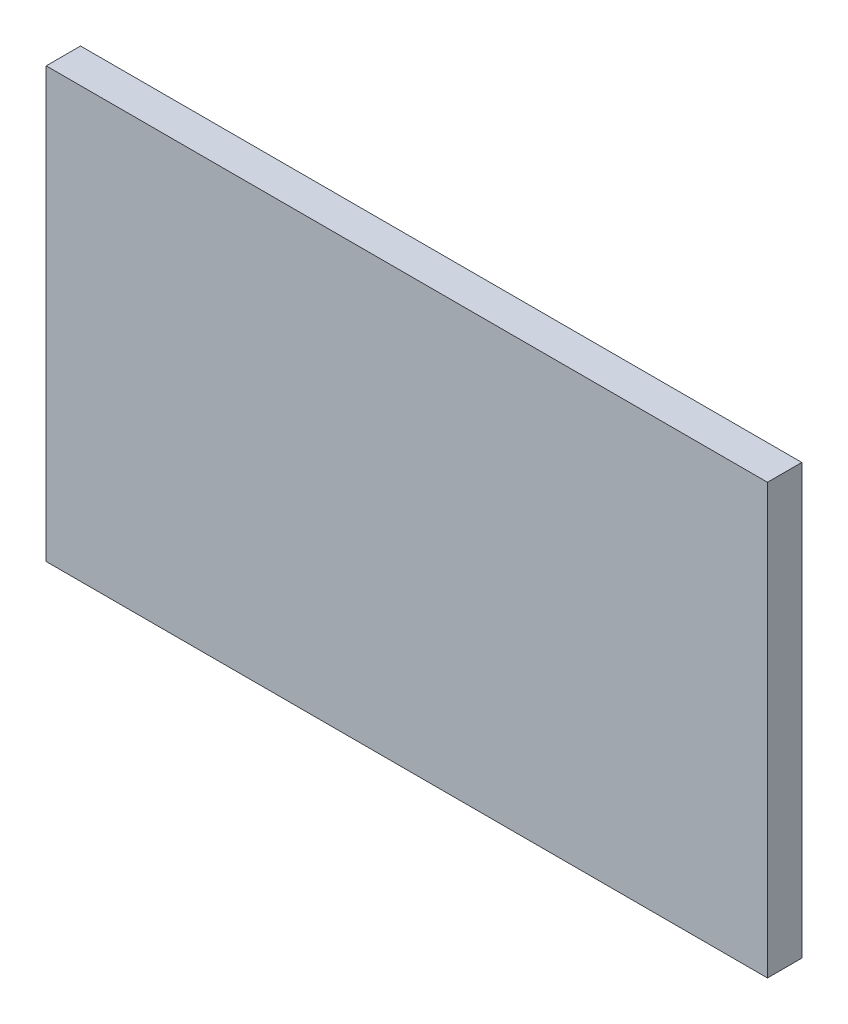
from build123d import *

# Parameters (mm, degrees)
SKETCH_1_W      = 420
SKETCH_1_H      = 250
EXTRUDE_1_DEPTH = 20


with BuildPart() as part:
    # ｽｹｯﾁ1 → ﾎﾞｽ - 押し出し1 (new body)
    with BuildSketch(Plane.XY):
        with Locations((210, 125)):
            Rectangle(SKETCH_1_W, SKETCH_1_H)
    extrude(amount=EXTRUDE_1_DEPTH)


solid = part.part
